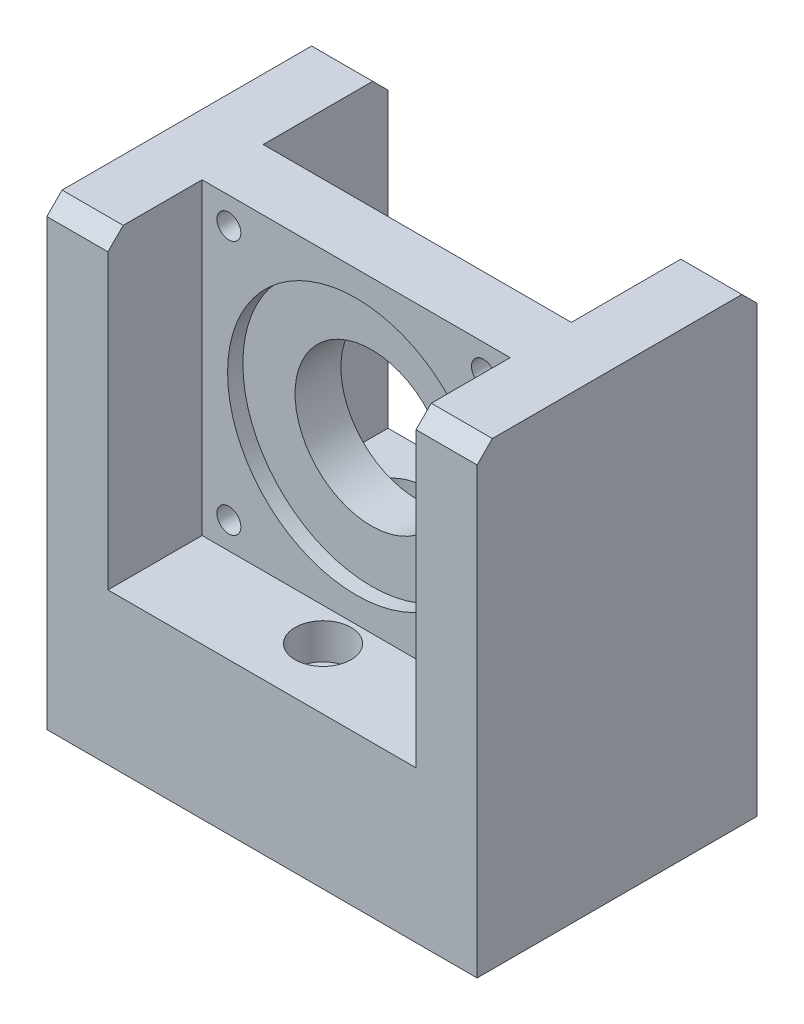
from build123d import *

# Parameters (mm, degrees)
SKETCH1_W           = 60.5
SKETCH1_H           = 60.5
SKETCH1_R           = 15
SKETCH1_R_2         = 2.35
BOSS_EXTRUDE1_DEPTH = 6
SKETCH2_R           = 25.25
CUT_EXTRUDE1_DEPTH  = 3
SKETCH3_W           = 84.5
SKETCH3_H           = 55
BOSS_EXTRUDE2_DEPTH = 29.75
SKETCH4_W           = 55
SKETCH4_H           = 60.5
BOSS_EXTRUDE3_DEPTH = 12
SKETCH5_W           = 55
SKETCH5_H           = 60.5
BOSS_EXTRUDE4_DEPTH = 12
CHAMFER1_SIZE       = 3
SKETCH6_R           = 3.05
CUT_EXTRUDE2_DEPTH  = 30.75
SKETCH7_R           = 5.5
CUT_EXTRUDE3_DEPTH  = 7


with BuildPart() as part:
    # Sketch1 → Boss-Extrude1 (new body, symmetric)
    with BuildSketch(Plane.XY):
        Rectangle(SKETCH1_W, SKETCH1_H)
        Circle(SKETCH1_R, mode=Mode.SUBTRACT)
        with Locations((-25, 25)):
            Circle(SKETCH1_R_2, mode=Mode.SUBTRACT)
        with Locations((25, 25)):
            Circle(SKETCH1_R_2, mode=Mode.SUBTRACT)
        with Locations((25, -25)):
            Circle(SKETCH1_R_2, mode=Mode.SUBTRACT)
        with Locations((-25, -25)):
            Circle(SKETCH1_R_2, mode=Mode.SUBTRACT)
    extrude(amount=BOSS_EXTRUDE1_DEPTH, both=True)

    # Sketch2 → Cut-Extrude1 (cut)
    with BuildSketch(Plane.XY.offset(6)):
        Circle(SKETCH2_R)
    extrude(amount=-CUT_EXTRUDE1_DEPTH, mode=Mode.SUBTRACT)

    # Sketch3 → Boss-Extrude2 (add)
    with BuildSketch(Plane.XZ.offset(30.25)):
        with Locations((0, -3)):
            Rectangle(SKETCH3_W, SKETCH3_H)
    extrude(amount=BOSS_EXTRUDE2_DEPTH)

    # Sketch4 → Boss-Extrude3 (add)
    with BuildSketch(Plane(origin=(30.25, 0, 0), x_dir=(0, 0, -1), z_dir=(1, 0, 0))):
        with Locations((3, 0)):
            Rectangle(SKETCH4_W, SKETCH4_H)
    extrude(amount=BOSS_EXTRUDE3_DEPTH)

    # Sketch5 → Boss-Extrude4 (add)
    with BuildSketch(Plane.ZY.offset(30.25)):
        with Locations((-3, 0)):
            Rectangle(SKETCH5_W, SKETCH5_H)
    extrude(amount=BOSS_EXTRUDE4_DEPTH)

    # Chamfer1
    chamfer1_edges = [part.edges().sort_by_distance(p)[0] for p in [
        (36.25, 30.25, 24.5),
        (36.25, 30.25, -30.5),
        (-36.25, 30.25, -30.5),
        (-36.25, 30.25, 24.5),
    ]]
    chamfer(chamfer1_edges, length=CHAMFER1_SIZE)

    # Sketch6 → Cut-Extrude2 (cut, through all)
    with BuildSketch(Plane(origin=(0, -30.25, 0), x_dir=(1, 0, 0), z_dir=(0, 1, 0))):
        with Locations((0, -12.5)):
            Circle(SKETCH6_R)
        with Locations((-17.5, 18.5)):
            Circle(SKETCH6_R)
        with Locations((17.5, 18.5)):
            Circle(SKETCH6_R)
    extrude(amount=-CUT_EXTRUDE2_DEPTH, mode=Mode.SUBTRACT)

    # Sketch7 → Cut-Extrude3 (cut)
    with BuildSketch(Plane(origin=(0, -30.25, 0), x_dir=(1, 0, 0), z_dir=(0, 1, 0))):
        with Locations((-17.5, 18.5)):
            Circle(SKETCH7_R)
        with Locations((17.5, 18.5)):
            Circle(SKETCH7_R)
        with Locations((0, -12.5)):
            Circle(SKETCH7_R)
    extrude(amount=-CUT_EXTRUDE3_DEPTH, mode=Mode.SUBTRACT)


solid = part.part
